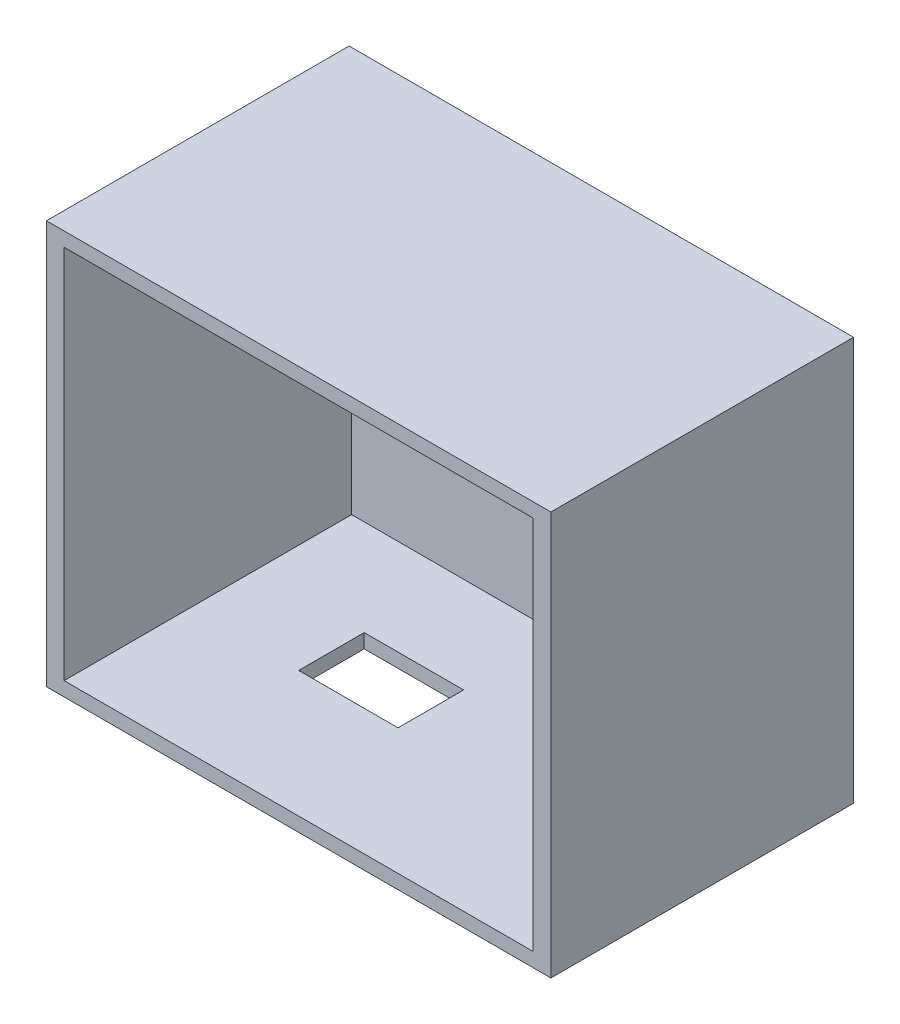
from build123d import *

# Parameters (mm, degrees)
ESBO_O1_W                  = 100
ESBO_O1_H                  = 80
RESSALTO_EXTRUS_O1_DEPTH   = 3
ESBO_O2_W                  = 100
ESBO_O2_H                  = 80
ESBO_O2_W_2                = 93
ESBO_O2_H_2                = 74.4
RESSALTO_EXTRUS_O2_DEPTH   = 60
ESBO_O3_W                  = 19.7
ESBO_O3_H                  = 13
CORTE_EXTRUS_O1_DEPTH      = 10
CORTE_EXTRUS_O1_DEPTH_BACK = 17


with BuildPart() as part:
    # Esboço1 → Ressalto-extrusão1 (new body)
    with BuildSketch(Plane.XY):
        with Locations((50, 40)):
            Rectangle(ESBO_O1_W, ESBO_O1_H)
    extrude(amount=RESSALTO_EXTRUS_O1_DEPTH)

    # Esboço2 → Ressalto-extrusão2 (add)
    with BuildSketch(Plane.XY):
        with Locations((50, 40)):
            Rectangle(ESBO_O2_W, ESBO_O2_H)
        with Locations((50, 40)):
            Rectangle(ESBO_O2_W_2, ESBO_O2_H_2, mode=Mode.SUBTRACT)
    extrude(amount=RESSALTO_EXTRUS_O2_DEPTH)

    # Esboço3 → Corte-extrusão1 (cut, two sides)
    with BuildSketch(Plane(origin=(0, 0, 0), x_dir=(1, 0, 0), z_dir=(0, 1, 0))) as corte_extrus_o1_sk:
        with Locations((34.85, -28.5)):
            Rectangle(ESBO_O3_W, ESBO_O3_H)
    extrude(amount=CORTE_EXTRUS_O1_DEPTH, mode=Mode.SUBTRACT)
    extrude(corte_extrus_o1_sk.sketch, amount=-CORTE_EXTRUS_O1_DEPTH_BACK, mode=Mode.SUBTRACT)


solid = part.part
